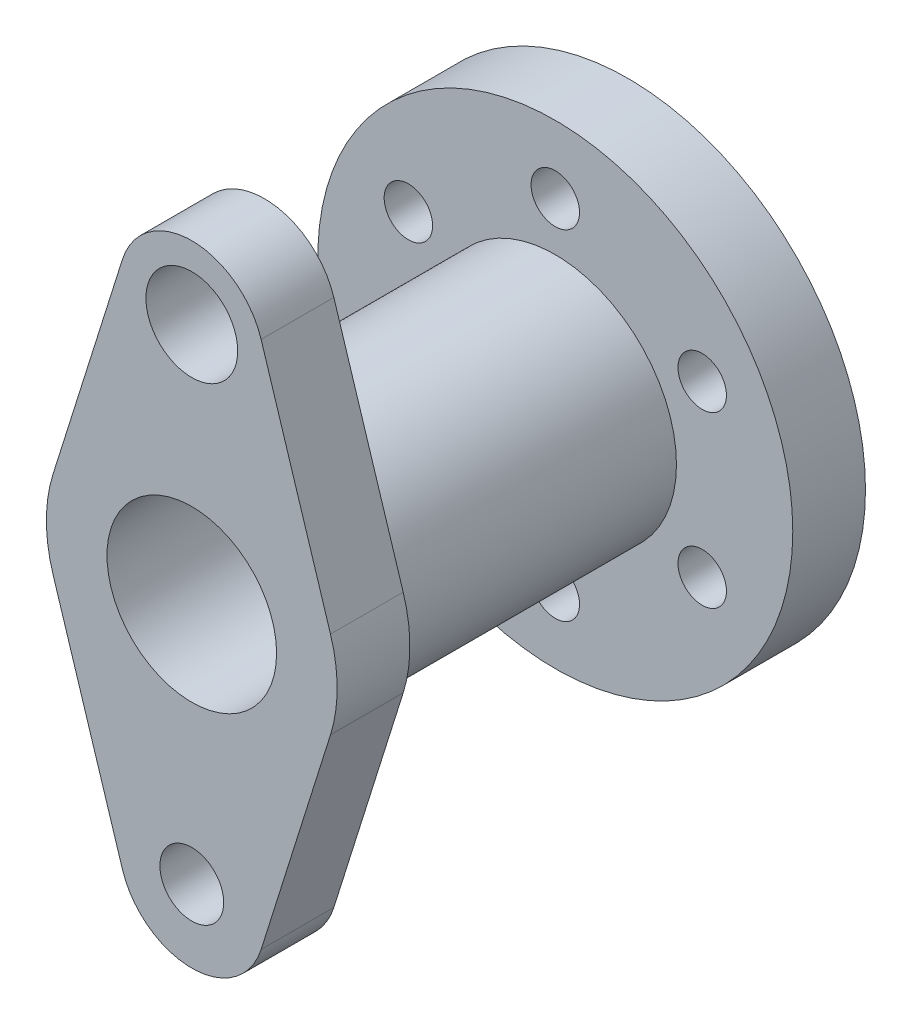
from build123d import *

# Parameters (mm, degrees)
SKETCH1_R           = 49
SKETCH1_R_2         = 5
SKETCH1_R_3         = 25
BOSS_EXTRUDE1_DEPTH = 15
SKETCH2_R           = 25
SKETCH2_R_2         = 13
BOSS_EXTRUDE2_DEPTH = 45
SKETCH3_R           = 25
SKETCH3_R_2         = 17.5
BOSS_EXTRUDE3_DEPTH = 30
SKETCH5_R           = 6.582974729
SKETCH5_R_2         = 9.465771496
BOSS_EXTRUDE5_DEPTH = 15
SKETCH6_R           = 17.5
CUT_EXTRUDE1_DEPTH  = 15


with BuildPart() as part:
    # Sketch1 → Boss-Extrude1 (new body)
    with BuildSketch(Plane.XY):
        Circle(SKETCH1_R)
        with Locations((0, 35)):
            Circle(SKETCH1_R_2, mode=Mode.SUBTRACT)
        with Locations((-30.310889132, 17.5)):
            Circle(SKETCH1_R_2, mode=Mode.SUBTRACT)
        with Locations((30.310889132, 17.5)):
            Circle(SKETCH1_R_2, mode=Mode.SUBTRACT)
        with Locations((30.310889132, -17.5)):
            Circle(SKETCH1_R_2, mode=Mode.SUBTRACT)
        with Locations((0, -35)):
            Circle(SKETCH1_R_2, mode=Mode.SUBTRACT)
        with Locations((-30.310889132, -17.5)):
            Circle(SKETCH1_R_2, mode=Mode.SUBTRACT)
        Circle(SKETCH1_R_3, mode=Mode.SUBTRACT)
    extrude(amount=BOSS_EXTRUDE1_DEPTH)

    # Sketch2 → Boss-Extrude2 (add)
    with BuildSketch(Plane.XY):
        Circle(SKETCH2_R)
        Circle(SKETCH2_R_2, mode=Mode.SUBTRACT)
    extrude(amount=BOSS_EXTRUDE2_DEPTH)

    # Sketch3 → Boss-Extrude3 (add)
    with BuildSketch(Plane.XY.offset(45)):
        Circle(SKETCH3_R)
        Circle(SKETCH3_R_2, mode=Mode.SUBTRACT)
    extrude(amount=BOSS_EXTRUDE3_DEPTH)

    # Sketch5 → Boss-Extrude5 (add)
    with BuildSketch(Plane.XY.offset(75)):
        with BuildLine():
            Line((14.309088021, -54.5), (28.618175978, -9.000000204))
            ThreePointArc((28.618175978, -9.000000204), (30, 3.7e-08), (28.618175956, 9.000000276))
            Line((28.618175956, 9.000000276), (14.309088021, 54.5))
            ThreePointArc((14.309088021, 54.5), (0, 65), (-14.309088021, 54.5))
            Line((-14.309088021, 54.5), (-28.618175825, 9.000000693))
            ThreePointArc((-28.618175825, 9.000000693), (-30, 2.3e-08), (-28.618175838, -9.000000649))
            Line((-28.618175838, -9.000000649), (-14.309088021, -54.5))
            ThreePointArc((-14.309088021, -54.5), (0, -65), (14.309088021, -54.5))
        make_face()
        with Locations((0, -50)):
            Circle(SKETCH5_R, mode=Mode.SUBTRACT)
        with Locations((0, 50)):
            Circle(SKETCH5_R_2, mode=Mode.SUBTRACT)
    extrude(amount=BOSS_EXTRUDE5_DEPTH)

    # Sketch6 → Cut-Extrude1 (cut)
    with BuildSketch(Plane.XY.offset(90)):
        Circle(SKETCH6_R)
    extrude(amount=-CUT_EXTRUDE1_DEPTH, mode=Mode.SUBTRACT)


solid = part.part
